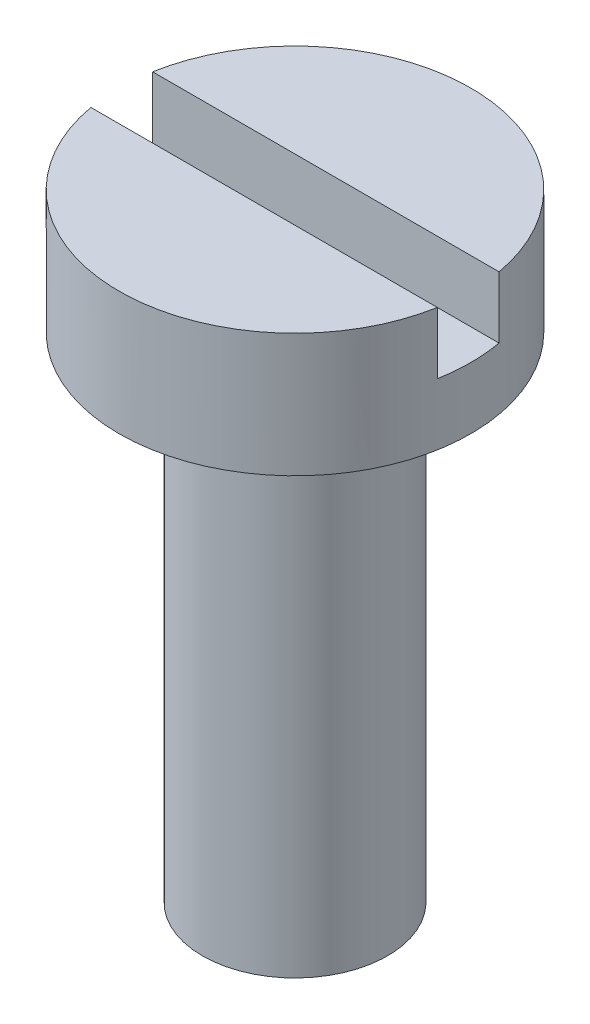
from build123d import *

# Parameters (mm, degrees)
SKETCH1_R           = 2.85
BOSS_EXTRUDE1_DEPTH = 2
SKETCH2_R           = 1.5
BOSS_EXTRUDE2_DEPTH = 8
SKETCH3_W           = 6
SKETCH3_H           = 1
CUT_EXTRUDE1_DEPTH  = 1


with BuildPart() as part:
    # Sketch1 → Boss-Extrude1 (new body)
    with BuildSketch(Plane(origin=(0, 0, 0), x_dir=(1, 0, 0), z_dir=(0, 1, 0))):
        Circle(SKETCH1_R)
    extrude(amount=BOSS_EXTRUDE1_DEPTH)

    # Sketch2 → Boss-Extrude2 (add)
    with BuildSketch(Plane(origin=(0, 0, 0), x_dir=(1, 0, 0), z_dir=(0, 1, 0))):
        Circle(SKETCH2_R)
    extrude(amount=-BOSS_EXTRUDE2_DEPTH)

    # Sketch3 → Cut-Extrude1 (cut)
    with BuildSketch(Plane(origin=(0, 2, 0), x_dir=(1, 0, 0), z_dir=(0, 1, 0))):
        Rectangle(SKETCH3_W, SKETCH3_H)
    extrude(amount=-CUT_EXTRUDE1_DEPTH, mode=Mode.SUBTRACT)


solid = part.part
